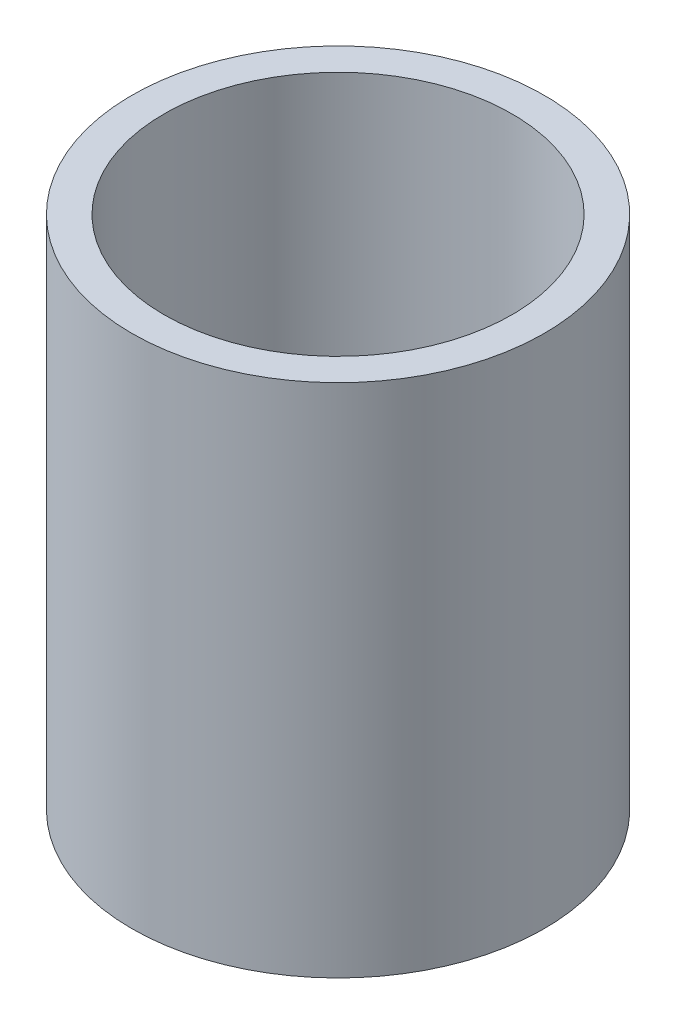
from build123d import *

# Parameters (mm, degrees)
SKETCH1_R               = 20.32
BOSS_EXTRUDE1_DEPTH     = 50.8
SHELL1_T                = -3.175
SKETCH2_R               = 4.064
CUT_EXTRUDE1_DEPTH      = 56.623245366
CUT_EXTRUDE1_DEPTH_BACK = 46.482


with BuildPart() as part:
    # Sketch1 → Boss-Extrude1 (new body)
    with BuildSketch(Plane(origin=(0, 0, 0), x_dir=(1, 0, 0), z_dir=(0, 1, 0))):
        with Locations(Location((0, 0, 0), (0, 0, 270))):
            Circle(SKETCH1_R)
    extrude(amount=BOSS_EXTRUDE1_DEPTH)

    # Shell1
    shell1_openings = [part.faces().sort_by_distance(p)[0] for p in [
        (0, 50.8, 0),
    ]]
    offset(amount=SHELL1_T, openings=shell1_openings, kind=Kind.INTERSECTION)

    # Sketch2 → Cut-Extrude1 (cut, two sides)
    with BuildSketch(Plane(origin=(0, 3.175, 0), x_dir=(1, 0, 0), z_dir=(0, 1, 0))) as cut_extrude1_sk:
        with Locations(Location((0, 0, 0), (0, 0, 270))):
            Circle(SKETCH2_R)
    extrude(amount=CUT_EXTRUDE1_DEPTH, mode=Mode.SUBTRACT)
    extrude(cut_extrude1_sk.sketch, amount=-CUT_EXTRUDE1_DEPTH_BACK, mode=Mode.SUBTRACT)


solid = part.part
